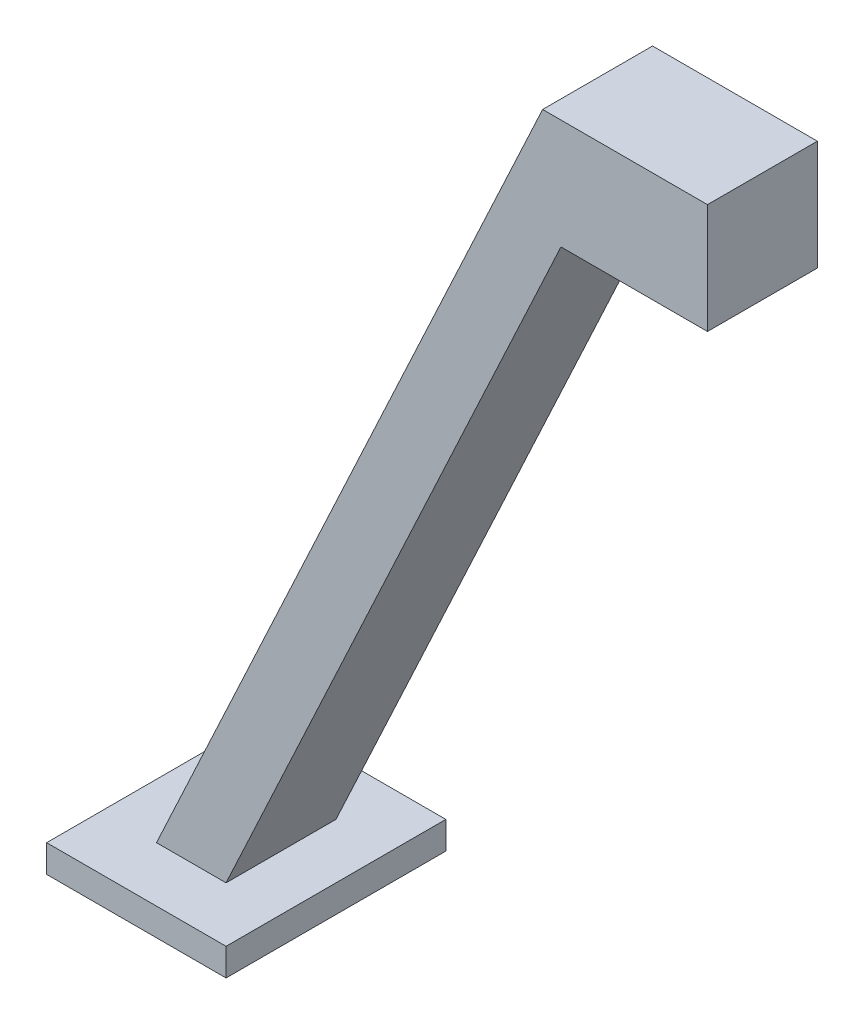
from build123d import *

# Parameters (mm, degrees)
BOSS_EXTRUDE1_DEPTH = 20
SKETCH2_W           = 32.657953652
SKETCH2_H           = 40
BOSS_EXTRUDE2_DEPTH = 5
SKETCH3_R           = 2.5
CUT_EXTRUDE1_DEPTH  = 1


with BuildPart() as part:
    # Sketch1 → Boss-Extrude1 (new body)
    with BuildSketch(Plane.XY):
        Polygon((-11.668199512, -10), (-72.614610432, -140.7), (-85.272564084, -140.7), (-15, 10), (15, 10), (15, -10), align=None)
    extrude(amount=BOSS_EXTRUDE1_DEPTH)

    # Sketch2 → Boss-Extrude2 (add)
    with BuildSketch(Plane.XZ.offset(140.7)):
        with Locations((-78.943587258, 10)):
            Rectangle(SKETCH2_W, SKETCH2_H)
    extrude(amount=BOSS_EXTRUDE2_DEPTH)

    # Sketch3 → Cut-Extrude1 (cut)
    with BuildSketch(Plane.XZ.offset(10)):
        with Locations((4.736957345, 9.180800469)):
            Circle(SKETCH3_R)
    extrude(amount=-CUT_EXTRUDE1_DEPTH, mode=Mode.SUBTRACT)


solid = part.part
